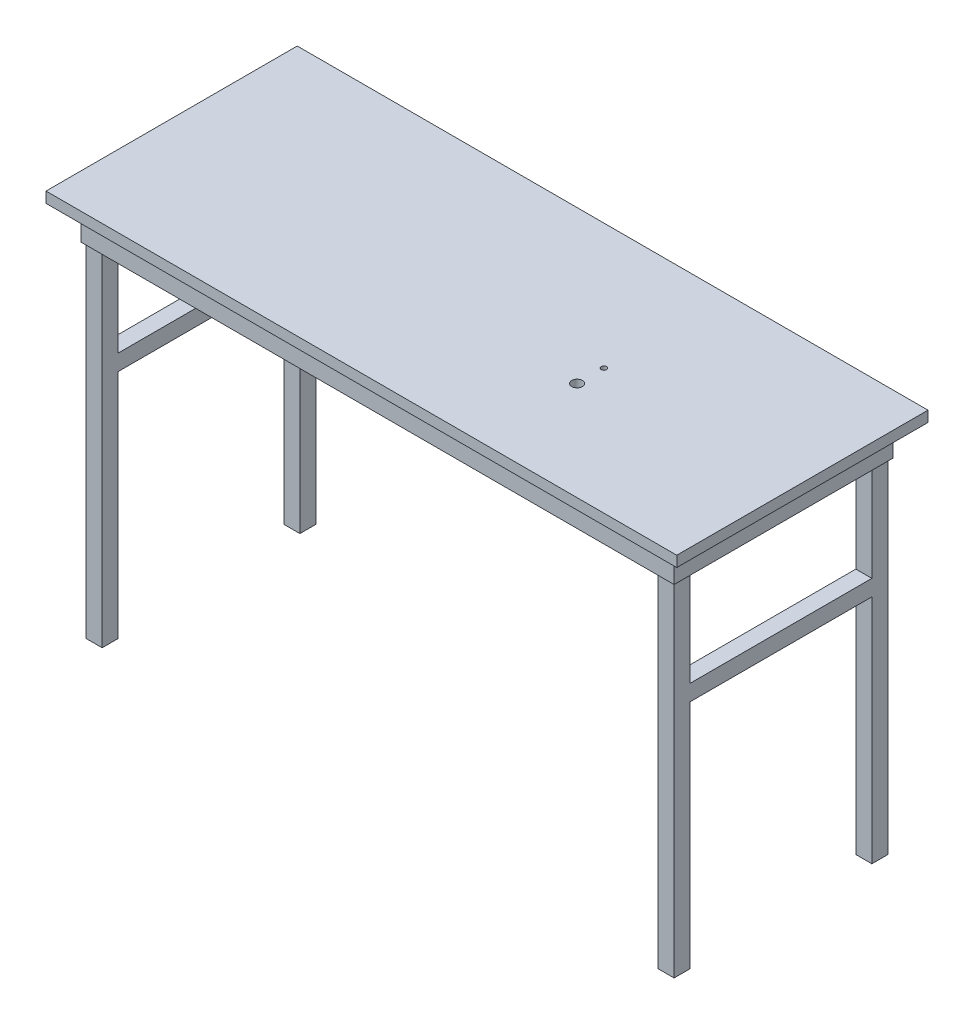
from build123d import *

# Parameters (mm, degrees)
SKETCH1_W                  = 1498.6
SKETCH1_H                  = 596.9
BOSS_EXTRUDE1_DEPTH        = 25.4
SKETCH3_W                  = 38.1
SKETCH3_H                  = 38.1
BOSS_EXTRUDE2_DEPTH        = 917.575
SKETCH4_W                  = 508
SKETCH4_H                  = 38.1
BOSS_EXTRUDE3_DEPTH        = 38.1
F_1_2_0_5_DIAMETER_HOLE1_D = 12.7
SKETCH9_W                  = 1409.7
SKETCH9_H                  = 520.7
SKETCH9_W_2                = 1397
SKETCH9_H_2                = 508
BOSS_EXTRUDE4_DEPTH        = 76.2
F_1_1_DIAMETER_HOLE3_D     = 25.4


with BuildPart() as part:
    # Sketch1 → Boss-Extrude1 (new body)
    with BuildSketch(Plane(origin=(0, 0, 0), x_dir=(1, 0, 0), z_dir=(0, 1, 0))):
        Rectangle(SKETCH1_W, SKETCH1_H)
    extrude(amount=BOSS_EXTRUDE1_DEPTH)

    # Sketch3 → Boss-Extrude2 (add)
    with BuildSketch(Plane.XZ.offset(-25.4)):
        with Locations((-679.45, 234.95)):
            Rectangle(SKETCH3_W, SKETCH3_H)
        with Locations((679.45, 234.95)):
            Rectangle(SKETCH3_W, SKETCH3_H)
        with Locations((679.45, -234.95)):
            Rectangle(SKETCH3_W, SKETCH3_H)
        with Locations((-679.45, -234.95)):
            Rectangle(SKETCH3_W, SKETCH3_H)
    extrude(amount=BOSS_EXTRUDE2_DEPTH)

    # Sketch4 → Boss-Extrude3 (add)
    with BuildSketch(Plane(origin=(698.5, 0, 0), x_dir=(0, 0, -1), z_dir=(1, 0, 0))):
        with Locations((0, -323.85)):
            Rectangle(SKETCH4_W, SKETCH4_H)
    boss_extrude3 = extrude(amount=-BOSS_EXTRUDE3_DEPTH)

    # Mirror1: Boss-Extrude3 across plane
    add(boss_extrude3.mirror(Plane(origin=(0, 0, 0), x_dir=(0, 0, 1), z_dir=(1, 0, 0))))

    # 1/2 (0.5) Diameter Hole1 (through all)
    with Locations(Plane(origin=(0, 25.4, 0), x_dir=(1, 0, 0), z_dir=(0, 1, 0))):
        with Locations((277.712499946, 0)):
            Hole(F_1_2_0_5_DIAMETER_HOLE1_D / 2)

    # Sketch9 → Boss-Extrude4 (add)
    with BuildSketch(Plane.XZ):
        Rectangle(SKETCH9_W, SKETCH9_H)
        Rectangle(SKETCH9_W_2, SKETCH9_H_2, mode=Mode.SUBTRACT)
    extrude(amount=BOSS_EXTRUDE4_DEPTH)

    # 1 (1) Diameter Hole3 (through all)
    with Locations(Plane(origin=(0, 25.4, 0), x_dir=(1, 0, 0), z_dir=(0, 1, 0))):
        with Locations((277.712499946, -63.5)):
            Hole(F_1_1_DIAMETER_HOLE3_D / 2)


solid = part.part
